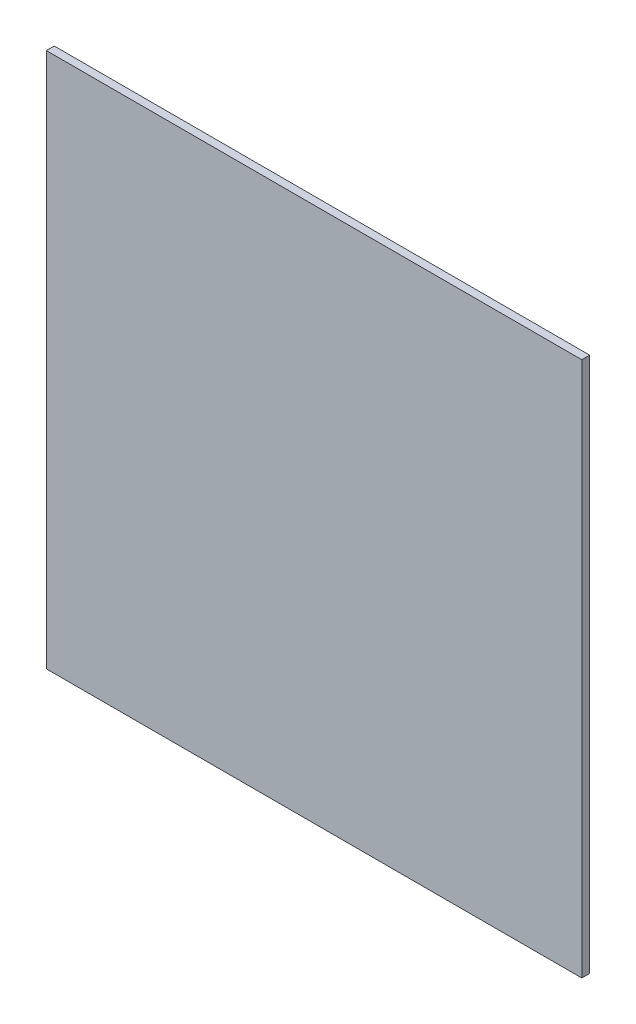
from build123d import *

# Parameters (mm, degrees)
BOSS_EXTRUDE1_START = 8
SKETCH1_W           = 1220
SKETCH1_H           = 1220
BOSS_EXTRUDE1_DEPTH = 18


with BuildPart() as part:
    # Sketch1 → Boss-Extrude1 (new body)
    with BuildSketch(Plane.XY.offset(BOSS_EXTRUDE1_START)):
        Rectangle(SKETCH1_W, SKETCH1_H)
    extrude(amount=-BOSS_EXTRUDE1_DEPTH)


solid = part.part
